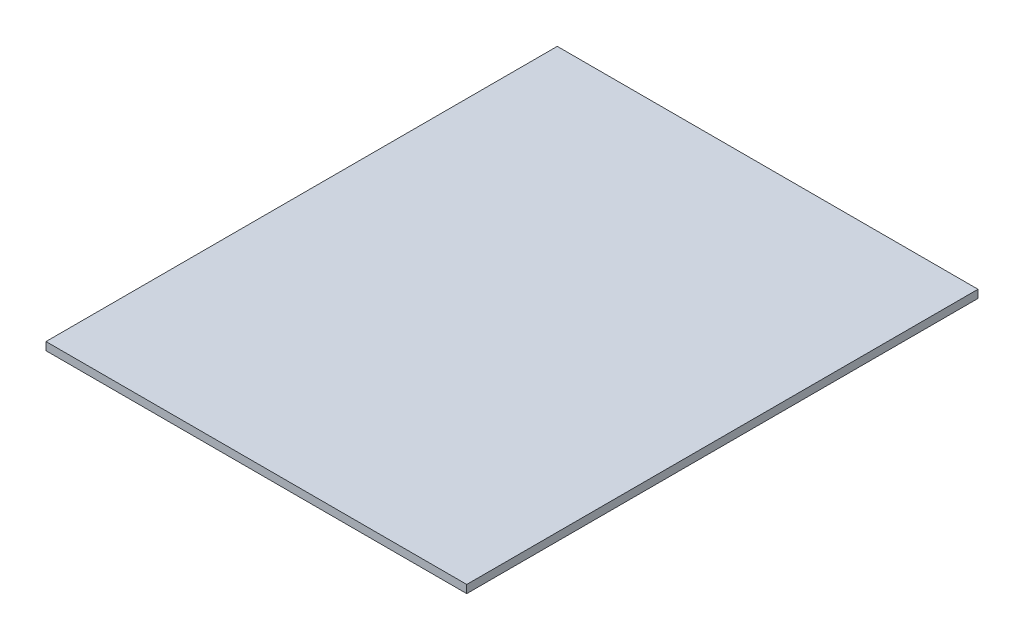
from build123d import *

# Parameters (mm, degrees)
SKETCH1_W           = 250.825
SKETCH1_H           = 304.8
BOSS_EXTRUDE1_DEPTH = 4.7625


with BuildPart() as part:
    # Sketch1 → Boss-Extrude1 (new body)
    with BuildSketch(Plane(origin=(0, 0, 0), x_dir=(1, 0, 0), z_dir=(0, 1, 0))):
        with Locations((125.4125, -152.4)):
            Rectangle(SKETCH1_W, SKETCH1_H)
    extrude(amount=BOSS_EXTRUDE1_DEPTH)


solid = part.part
